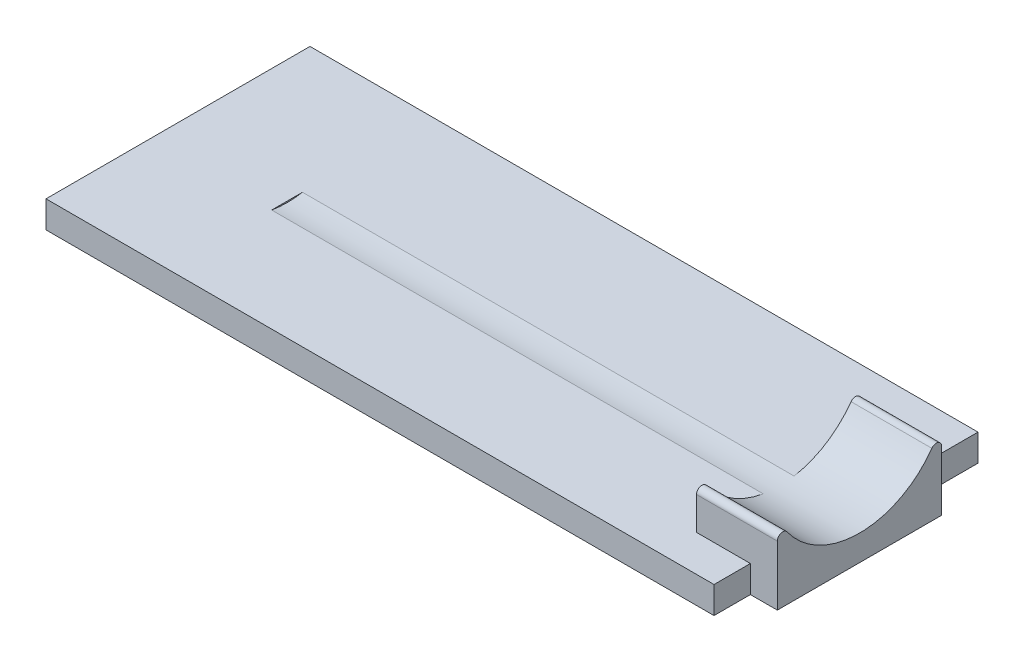
from build123d import *

# Parameters (mm, degrees)
SKETCH1_W           = 24.8
SKETCH1_H           = 9.8
BOSS_EXTRUDE1_DEPTH = 1
SKETCH2_W           = 3
SKETCH2_H           = 6.1
BOSS_EXTRUDE2_DEPTH = 3.25
SKETCH4_W           = 1
SKETCH4_H           = 6.1
BOSS_EXTRUDE3_DEPTH = 1
SKETCH3_R           = 3.3
CUT_EXTRUDE1_DEPTH  = 21.25
FILLET1_R           = 0.2


with BuildPart() as part:
    # Sketch1 → Boss-Extrude1 (new body)
    with BuildSketch(Plane(origin=(0, 0, 0), x_dir=(1, 0, 0), z_dir=(0, 1, 0))):
        with Locations((-12.4, 4.9)):
            Rectangle(SKETCH1_W, SKETCH1_H)
    extrude(amount=BOSS_EXTRUDE1_DEPTH)

    # Sketch2 → Boss-Extrude2 (add)
    with BuildSketch(Plane(origin=(0, 1, 0), x_dir=(1, 0, 0), z_dir=(0, 1, 0))):
        with Locations((-0.5, 4.4)):
            Rectangle(SKETCH2_W, SKETCH2_H)
    extrude(amount=BOSS_EXTRUDE2_DEPTH)

    # Sketch4 → Boss-Extrude3 (add)
    with BuildSketch(Plane.XZ.offset(-1)):
        with Locations((0.5, -4.4)):
            Rectangle(SKETCH4_W, SKETCH4_H)
    extrude(amount=BOSS_EXTRUDE3_DEPTH)

    # Sketch3 → Cut-Extrude1 (cut)
    with BuildSketch(Plane(origin=(1, 0, 0), x_dir=(0, 0, -1), z_dir=(1, 0, 0))):
        with Locations((4.4, 4.25)):
            Circle(SKETCH3_R)
    extrude(amount=-CUT_EXTRUDE1_DEPTH, mode=Mode.SUBTRACT)

    # Fillet1
    fillet1_edges = [part.edges().sort_by_distance(p)[0] for p in [
        (-0.5, 2.990039683, -1.35),
        (-0.5, 2.990039683, -7.45),
    ]]
    fillet(fillet1_edges, radius=FILLET1_R)


solid = part.part
